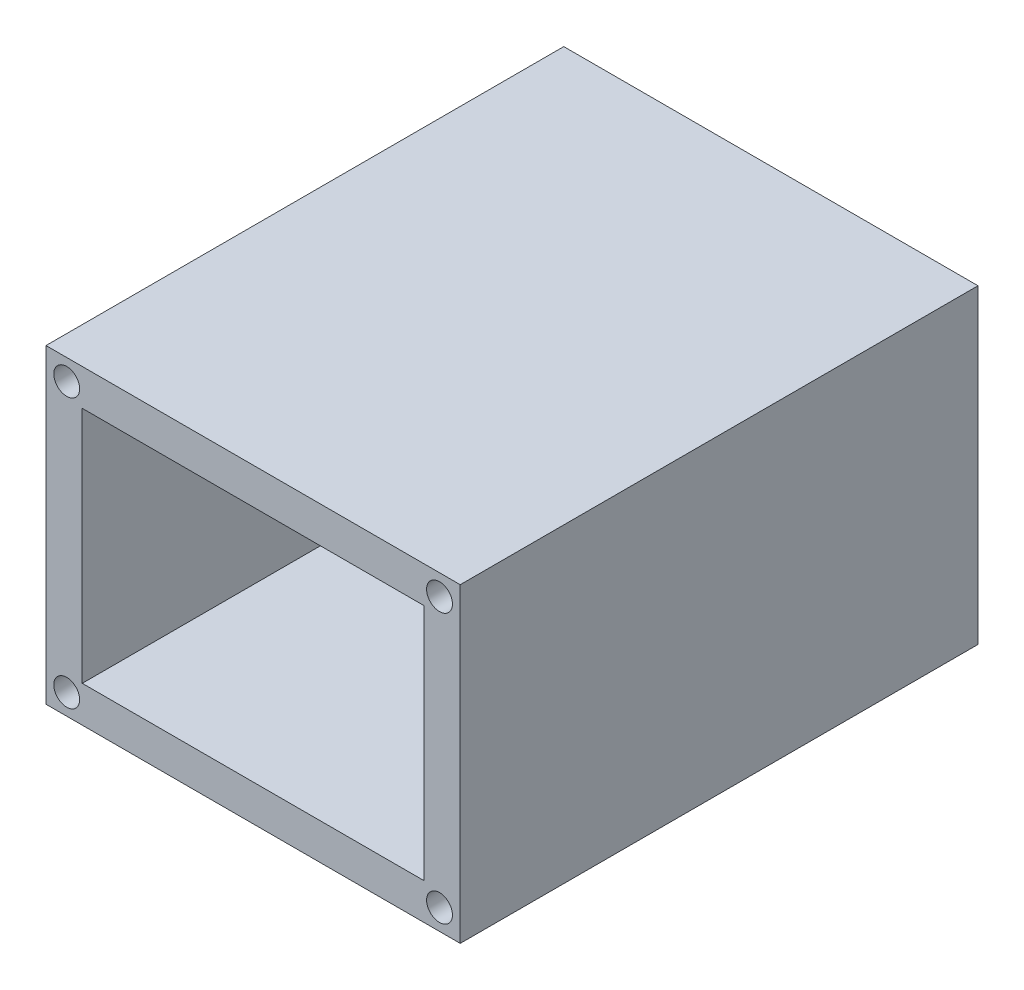
from build123d import *

# Parameters (mm, degrees)
SKETCH1_W           = 40
SKETCH1_H           = 30
BOSS_EXTRUDE1_DEPTH = 50
SKETCH3_W           = 33
SKETCH3_H           = 23
CUT_EXTRUDE1_DEPTH  = 51
SKETCH4_R           = 1.25
CUT_EXTRUDE2_DEPTH  = 10


with BuildPart() as part:
    # Sketch1 → Boss-Extrude1 (new body)
    with BuildSketch(Plane.XY):
        with Locations((20, 15)):
            Rectangle(SKETCH1_W, SKETCH1_H)
    extrude(amount=BOSS_EXTRUDE1_DEPTH)

    # Sketch3 → Cut-Extrude1 (cut, through all)
    with BuildSketch(Plane.XY.offset(50)):
        with Locations((20, 15)):
            Rectangle(SKETCH3_W, SKETCH3_H)
    extrude(amount=-CUT_EXTRUDE1_DEPTH, mode=Mode.SUBTRACT)

    # Sketch4 → Cut-Extrude2 (cut)
    with BuildSketch(Plane.XY.offset(50)):
        with Locations((38, 28)):
            Circle(SKETCH4_R)
        with Locations((2, 28)):
            Circle(SKETCH4_R)
        with Locations((2, 2)):
            Circle(SKETCH4_R)
        with Locations((38, 2)):
            Circle(SKETCH4_R)
    extrude(amount=-CUT_EXTRUDE2_DEPTH, mode=Mode.SUBTRACT)


solid = part.part
